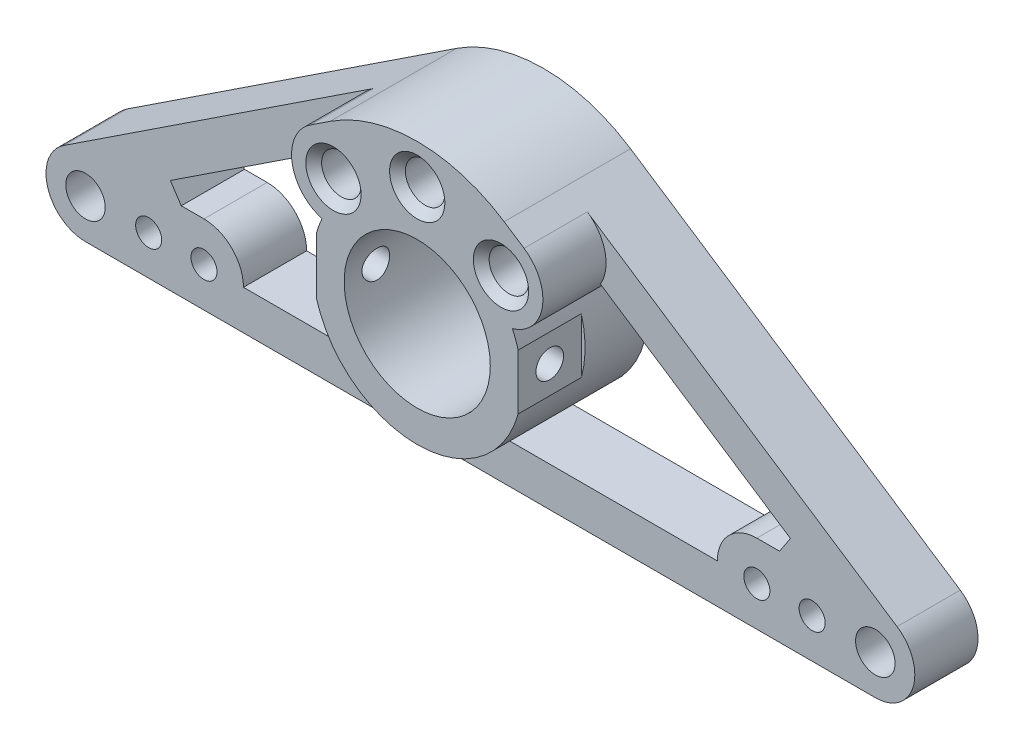
from build123d import *

# Parameters (mm, degrees)
SKETCH_1_R               = 9.25
SKETCH_1_R_2             = 2.5
EXTRUDE_1_DEPTH          = 8
SKETCH_2_R               = 2.5
CUT_EXTRUDE_1_DEPTH      = 9
CUT_EXTRUDE_2_DEPTH      = 9
SKETCH_8_R               = 9.25
SKETCH_8_R_2             = 2.5
EXTRUDE_2_DEPTH          = 8
SKETCH_9_R               = 1.75
CUT_EXTRUDE_5_DEPTH      = 56
CUT_EXTRUDE_5_DEPTH_BACK = 56
SKETCH_11_W              = 2.84011948
SKETCH_11_H              = 7
CUT_EXTRUDE_6_DEPTH      = 8
EXTRUDE_3_DEPTH          = 8
SKETCH_12_R              = 1.65
CUT_EXTRUDE_7_DEPTH      = 9
CHAMFER_2_SIZE           = 1


with BuildPart() as part:
    # Sketch 1 → Extrude 1 (new body)
    with BuildSketch(Plane.XY):
        with BuildLine():
            Line((-50, -20), (50, -20))
            ThreePointArc((50, -20), (54.789131426, -16.436739428), (52.752293578, -10.825688073))
            Line((52.752293578, -10.825688073), (11.009174312, 16.697247706))
            ThreePointArc((11.009174312, 16.697247706), (0, 20), (-11.009174312, 16.697247706))
            Line((-11.009174312, 16.697247706), (-52.752293578, -10.825688073))
            ThreePointArc((-52.752293578, -10.825688073), (-54.789131426, -16.436739428), (-50, -20))
        make_face()
        Circle(SKETCH_1_R, mode=Mode.SUBTRACT)
        with Locations((50, -15)):
            Circle(SKETCH_1_R_2, mode=Mode.SUBTRACT)
        with Locations((-50, -15)):
            Circle(SKETCH_1_R_2, mode=Mode.SUBTRACT)
    extrude(amount=EXTRUDE_1_DEPTH)

    # Sketch 2 → Cut-Extrude 1 (cut, through all)
    with BuildSketch(Plane.XY.offset(8)):
        with Locations((0, 15)):
            Circle(SKETCH_2_R)
        with Locations((-10.606601718, 10.606601718)):
            Circle(SKETCH_2_R)
        with Locations((10.606601718, 10.606601718)):
            Circle(SKETCH_2_R)
    extrude(amount=-CUT_EXTRUDE_1_DEPTH, mode=Mode.SUBTRACT)

    # Sketch 3 → Cut-Extrude 2 (cut, through all)
    with BuildSketch(Plane.XY.offset(8)):
        with BuildLine():
            Line((-44.573394495, -11.422018349), (-15.198052695, 7.946338883))
            ThreePointArc((-15.198052695, 7.946338883), (-13.864095006, 6.417668929), (-12.053948035, 5.501348633))
            ThreePointArc((-12.053948035, 5.501348633), (-12.001148515, -5.615597414), (-3.5, -12.779377919))
            Line((-3.5, -12.779377919), (-3.5, -15))
            Line((-3.5, -15), (-43.5, -15))
            ThreePointArc((-43.5, -15), (-43.774129146, -13.132238744), (-44.573394495, -11.422018349))
        make_face()
    cut_extrude_2 = extrude(amount=-CUT_EXTRUDE_2_DEPTH, mode=Mode.SUBTRACT)

    # Mirror 1: Cut-Extrude 2 across plane
    add(cut_extrude_2.mirror(Plane(origin=(0, 0, 0), x_dir=(0, 0, 1), z_dir=(1, 0, 0))), mode=Mode.SUBTRACT)

    # Sketch 8 → Extrude 2 (add)
    with BuildSketch(Plane.XY.offset(8)):
        with BuildLine():
            Line((-11.009174312, 16.697247706), (-13.527583827, 15.036757916))
            ThreePointArc((-13.527583827, 15.036757916), (-15.771645109, 11.823461278), (-15.198052695, 7.946338883))
            ThreePointArc((-15.198052695, 7.946338883), (-13.864095006, 6.417668929), (-12.053948035, 5.501348633))
            ThreePointArc((-12.053948035, 5.501348633), (-12.001148515, -5.615597414), (-3.5, -12.779377919))
            ThreePointArc((-3.5, -12.779377919), (0, -13.25), (3.5, -12.779377919))
            ThreePointArc((3.5, -12.779377919), (12.001148515, -5.615597414), (12.053948035, 5.501348633))
            ThreePointArc((12.053948035, 5.501348633), (13.864095006, 6.417668929), (15.198052695, 7.946338883))
            ThreePointArc((15.198052695, 7.946338883), (15.771645109, 11.823461278), (13.527583827, 15.036757916))
            Line((13.527583827, 15.036757916), (11.009174312, 16.697247706))
            ThreePointArc((11.009174312, 16.697247706), (0, 20), (-11.009174312, 16.697247706))
        make_face()
        Circle(SKETCH_8_R, mode=Mode.SUBTRACT)
        with Locations((-10.606601718, 10.606601718)):
            Circle(SKETCH_8_R_2, mode=Mode.SUBTRACT)
        with Locations((10.606601718, 10.606601718)):
            Circle(SKETCH_8_R_2, mode=Mode.SUBTRACT)
        with Locations((0, 15)):
            Circle(SKETCH_8_R_2, mode=Mode.SUBTRACT)
    extrude(amount=EXTRUDE_2_DEPTH)

    # Sketch 9 → Cut-Extrude 5 (cut, two sides)
    with BuildSketch(Plane(origin=(0, 0, 0), x_dir=(0, 0, -1), z_dir=(1, 0, 0))) as cut_extrude_5_sk:
        with Locations((-12, 0)):
            Circle(SKETCH_9_R)
    extrude(amount=CUT_EXTRUDE_5_DEPTH, mode=Mode.SUBTRACT)
    extrude(cut_extrude_5_sk.sketch, amount=-CUT_EXTRUDE_5_DEPTH_BACK, mode=Mode.SUBTRACT)

    # Sketch 11 → Cut-Extrude 6 (cut)
    with BuildSketch(Plane.XY.offset(16)):
        with Locations((14.199437659, 0)):
            Rectangle(SKETCH_11_W, SKETCH_11_H)
        with Locations((-14.199437659, 0)):
            Rectangle(SKETCH_11_W, SKETCH_11_H)
    extrude(amount=-CUT_EXTRUDE_6_DEPTH, mode=Mode.SUBTRACT)

    # Sketch 13 → Extrude 3 (add)
    with BuildSketch(Plane.XY.offset(8)):
        with BuildLine():
            Line((-37.875, -10), (-35, -10))
            ThreePointArc((-35, -10), (-30, -15), (-35, -20))
            Line((-35, -20), (-44.573394495, -20))
            Line((-44.573394495, -20), (-44.573394495, -11.422018349))
            Line((-44.573394495, -11.422018349), (-39.251146789, -7.912844037))
            Line((-39.251146789, -7.912844037), (-37.875, -10))
        make_face()
    extrude_3 = extrude(amount=-EXTRUDE_3_DEPTH)

    # Sketch 12 → Cut-Extrude 7 (cut, through all)
    with BuildSketch(Plane.XY.offset(8)):
        with Locations((-42, -15)):
            Circle(SKETCH_12_R)
        with Locations((-35, -15)):
            Circle(SKETCH_12_R)
    cut_extrude_7 = extrude(amount=-CUT_EXTRUDE_7_DEPTH, mode=Mode.SUBTRACT)

    # Mirror 2: Extrude 3, Cut-Extrude 7 across plane
    add(extrude_3.mirror(Plane(origin=(0, 0, 0), x_dir=(0, 0, 1), z_dir=(1, 0, 0))))
    add(cut_extrude_7.mirror(Plane(origin=(0, 0, 0), x_dir=(0, 0, 1), z_dir=(1, 0, 0))), mode=Mode.SUBTRACT)

    # Chamfer 2
    chamfer_2_edges = [part.edges().sort_by_distance(p)[0] for p in [
        (8.106601718, 10.606601718, 0),
        (-13.106601718, 10.606601718, 0),
        (-2.5, 15, 0),
        (-13.106601718, 10.606601718, 16),
        (-2.5, 15, 16),
        (8.106601718, 10.606601718, 16),
    ]]
    chamfer(chamfer_2_edges, length=CHAMFER_2_SIZE)


solid = part.part
